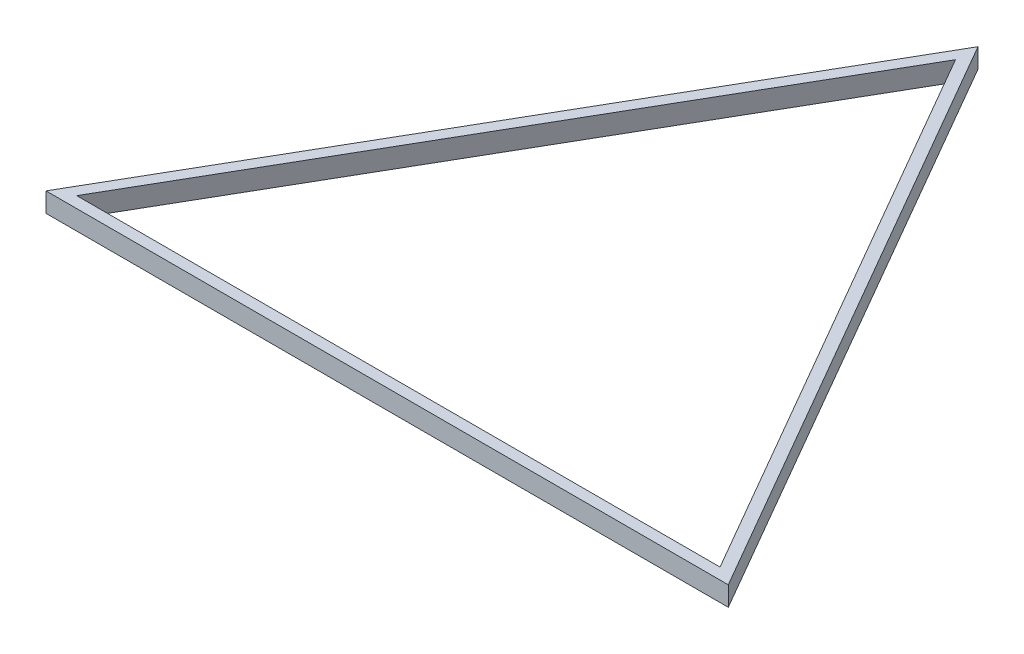
from build123d import *

# Parameters (mm, degrees)
BOSS_EXTRUDE1_DEPTH = 20


with BuildPart() as part:
    # Sketch1 → Boss-Extrude1 (new body)
    with BuildSketch(Plane(origin=(0, 0, 0), x_dir=(1, 0, 0), z_dir=(0, 1, 0))):
        Polygon((0, 404.145188433), (-350, -202.072594216), (350, -202.072594216), align=None)
        Polygon((0, 381.051177665), (-330, -190.525588833), (330, -190.525588833), align=None, mode=Mode.SUBTRACT)
    extrude(amount=BOSS_EXTRUDE1_DEPTH)


solid = part.part
